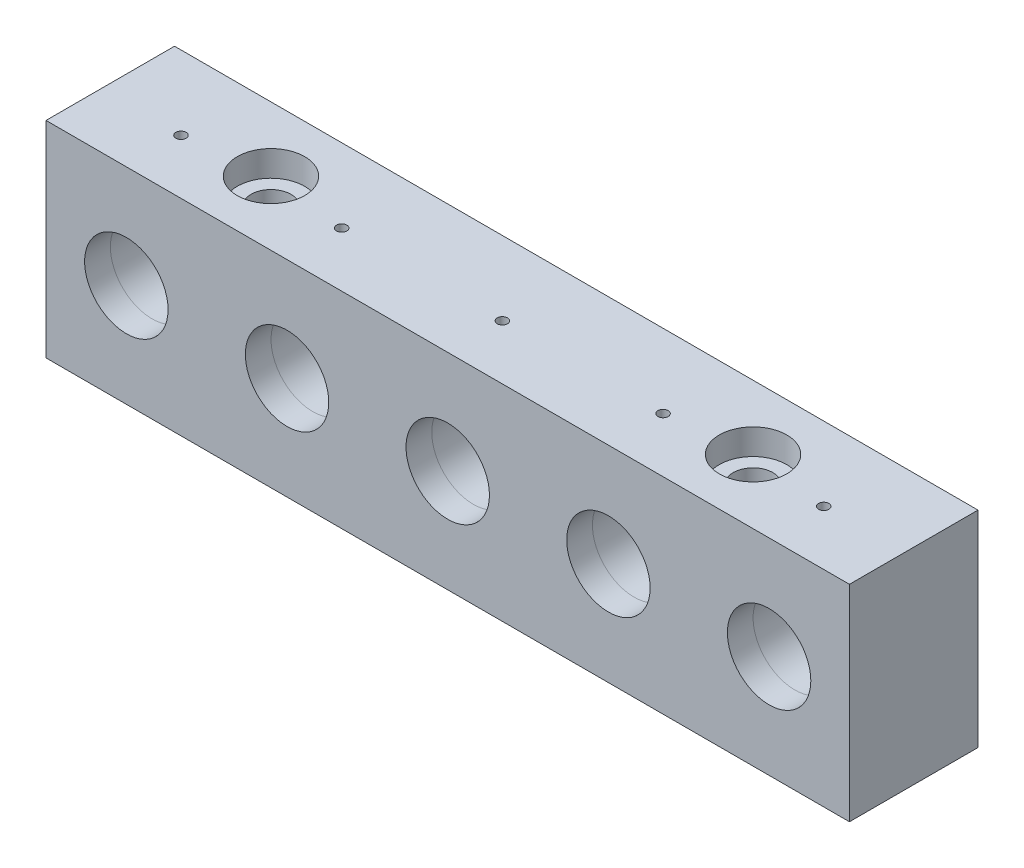
from build123d import *

# Parameters (mm, degrees)
SKETCH1_W                                           = 125
SKETCH1_H                                           = 20
BOSS_EXTRUDE1_DEPTH                                 = 32
SKETCH2_R                                           = 6.4897
CUT_EXTRUDE1_DEPTH                                  = 4
SKETCH3_R                                           = 6.5
CUT_EXTRUDE2_DEPTH                                  = 6.5
CUT_EXTRUDE4_REACH                                  = 132.572
SKETCH8_R                                           = 2.1
SKETCH9_R                                           = 2.825
CUT_EXTRUDE5_DEPTH                                  = 1.1
M3X0_5_TAPPED_HOLE1_AT_2_COUNT                      = 2
M3X0_5_TAPPED_HOLE1_AT_2_PITCH                      = 14
LPATTERN1_COUNT                                     = 5
LPATTERN1_PITCH                                     = 25
M2_TAPPED_HOLE1_REACH                               = 132.572
M2_TAPPED_HOLE1_BORE_R                              = 0.8
CBORE_FOR_M6_HEX_SOCKET_HEAD_CAP_SCREW1_D           = 6.2
CBORE_FOR_M6_HEX_SOCKET_HEAD_CAP_SCREW1_CBORE_D     = 10.5
CBORE_FOR_M6_HEX_SOCKET_HEAD_CAP_SCREW1_CBORE_DEPTH = 4


with BuildPart() as part:
    # Sketch1 → Boss-Extrude1 (new body)
    with BuildSketch(Plane(origin=(0, 0, 0), x_dir=(1, 0, 0), z_dir=(0, 1, 0))):
        with Locations((62.5, 10)):
            Rectangle(SKETCH1_W, SKETCH1_H)
    extrude(amount=BOSS_EXTRUDE1_DEPTH)

    # Sketch2 → Cut-Extrude1 (cut)
    with BuildSketch(Plane.XY):
        with Locations((12.5, 16)):
            Circle(SKETCH2_R)
    cut_extrude1 = extrude(amount=-CUT_EXTRUDE1_DEPTH, mode=Mode.SUBTRACT)

    # Sketch3 → Cut-Extrude2 (cut)
    with BuildSketch(Plane.XY.offset(-4)):
        with Locations((12.5, 16)):
            Circle(SKETCH3_R)
    cut_extrude2 = extrude(amount=-CUT_EXTRUDE2_DEPTH, mode=Mode.SUBTRACT)

    # Sketch6 → M12x0.5 Tapped Hole1 (revolve, cut)
    with BuildSketch(Plane(origin=(12.5, 16, -10.5), x_dir=(0, -1, 0), z_dir=(1, 0, 0))):
        Polygon((0, 0), (0, 7.454948559), (5.75, 4), (5.75, 0), align=None)
    m12x0_5_tapped_hole1 = revolve(axis=Axis((12.5, 16, -4.15), (0, 0, -1)), mode=Mode.SUBTRACT)

    # Sketch8 → Cut-Extrude4 (cut, up to next)
    with BuildSketch(Plane.XY, mode=Mode.PRIVATE) as cut_extrude4_sk1:
        with Locations((12.5, 16)):
            Circle(SKETCH8_R)
    cut_extrude4_tool1 = extrude(cut_extrude4_sk1.sketch, amount=-CUT_EXTRUDE4_REACH, mode=Mode.PRIVATE) & part.part
    cut_extrude4 = cut_extrude4_tool1.solids().sort_by_distance((12.5, 16, 0))[0]
    add(cut_extrude4, mode=Mode.SUBTRACT)

    # Sketch9 → Cut-Extrude5 (cut)
    with BuildSketch(Plane(origin=(0, 0, -20), x_dir=(-1, 0, 0), z_dir=(0, 0, -1))):
        with Locations((-12.5, 16)):
            Circle(SKETCH9_R)
    cut_extrude5 = extrude(amount=-CUT_EXTRUDE5_DEPTH, mode=Mode.SUBTRACT)

    # Sketch11 → M3x0.5 Tapped Hole1 (revolve, cut)
    with BuildSketch(Plane(origin=(19.5, 16, -20), x_dir=(0, 1, 0), z_dir=(1, 0, 0))):
        Polygon((0, 0), (0, 5.251075774), (1.25, 4.5), (1.25, 0), align=None)
    m3x0_5_tapped_hole1 = revolve(axis=Axis((19.5, 16, -26.35), (0, 0, 1)), mode=Mode.SUBTRACT)

    # M3x0.5 Tapped Hole1 at 2: M3x0.5 Tapped Hole1 ×2
    with Locations(*[(-i * M3X0_5_TAPPED_HOLE1_AT_2_PITCH, 0, 0) for i in range(1, M3X0_5_TAPPED_HOLE1_AT_2_COUNT)]):
        add(m3x0_5_tapped_hole1, mode=Mode.SUBTRACT)

    # LPattern1: Cut-Extrude1, Cut-Extrude2, M12x0.5 Tapped Hole1, Cut-Extrude4, Cut-Extrude5, M3x0.5 Tapped Hole1 ×5
    with Locations(*[(i * LPATTERN1_PITCH, 0, 0) for i in range(1, LPATTERN1_COUNT)]):
        add(cut_extrude1, mode=Mode.SUBTRACT)
        add(cut_extrude2, mode=Mode.SUBTRACT)
        add(m12x0_5_tapped_hole1, mode=Mode.SUBTRACT)
        add(cut_extrude4, mode=Mode.SUBTRACT)
        add(cut_extrude5, mode=Mode.SUBTRACT)
        add(m3x0_5_tapped_hole1, mode=Mode.SUBTRACT)

    # LPattern1 copy 1 sketch → LPattern1 copy 1 (revolve, cut)
    with BuildSketch(Plane(origin=(30.5, 16, -20), x_dir=(0, 1, 0), z_dir=(1, 0, 0))):
        Polygon((0, 0), (0, 5.251075774), (1.25, 4.5), (1.25, 0), align=None)
    revolve(axis=Axis((30.5, 16, -26.35), (0, 0, 1)), mode=Mode.SUBTRACT)

    # LPattern1 copy 2 sketch → LPattern1 copy 2 (revolve, cut)
    with BuildSketch(Plane(origin=(55.5, 16, -20), x_dir=(0, 1, 0), z_dir=(1, 0, 0))):
        Polygon((0, 0), (0, 5.251075774), (1.25, 4.5), (1.25, 0), align=None)
    revolve(axis=Axis((55.5, 16, -26.35), (0, 0, 1)), mode=Mode.SUBTRACT)

    # LPattern1 copy 3 sketch → LPattern1 copy 3 (revolve, cut)
    with BuildSketch(Plane(origin=(80.5, 16, -20), x_dir=(0, 1, 0), z_dir=(1, 0, 0))):
        Polygon((0, 0), (0, 5.251075774), (1.25, 4.5), (1.25, 0), align=None)
    revolve(axis=Axis((80.5, 16, -26.35), (0, 0, 1)), mode=Mode.SUBTRACT)

    # LPattern1 copy 4 sketch → LPattern1 copy 4 (revolve, cut)
    with BuildSketch(Plane(origin=(105.5, 16, -20), x_dir=(0, 1, 0), z_dir=(1, 0, 0))):
        Polygon((0, 0), (0, 5.251075774), (1.25, 4.5), (1.25, 0), align=None)
    revolve(axis=Axis((105.5, 16, -26.35), (0, 0, 1)), mode=Mode.SUBTRACT)

    # M2 Tapped Hole1 bore → M2 Tapped Hole1 (cut, up to next)
    with BuildSketch(Plane(origin=(0, 32, 0), x_dir=(1, 0, 0), z_dir=(0, 1, 0)), mode=Mode.PRIVATE) as m2_tapped_hole1_sk1:
        with Locations((12.5, 8.5)):
            Circle(M2_TAPPED_HOLE1_BORE_R)
    m2_tapped_hole1_tool1 = extrude(m2_tapped_hole1_sk1.sketch, amount=-M2_TAPPED_HOLE1_REACH, mode=Mode.PRIVATE) & part.part
    # M2 Tapped Hole1 bore → M2 Tapped Hole1 (cut, up to next)
    with BuildSketch(Plane(origin=(0, 32, 0), x_dir=(1, 0, 0), z_dir=(0, 1, 0)), mode=Mode.PRIVATE) as m2_tapped_hole1_sk2:
        with Locations((37.5, 8.5)):
            Circle(M2_TAPPED_HOLE1_BORE_R)
    m2_tapped_hole1_tool2 = extrude(m2_tapped_hole1_sk2.sketch, amount=-M2_TAPPED_HOLE1_REACH, mode=Mode.PRIVATE) & part.part
    # M2 Tapped Hole1 bore → M2 Tapped Hole1 (cut, up to next)
    with BuildSketch(Plane(origin=(0, 32, 0), x_dir=(1, 0, 0), z_dir=(0, 1, 0)), mode=Mode.PRIVATE) as m2_tapped_hole1_sk3:
        with Locations((62.5, 8.5)):
            Circle(M2_TAPPED_HOLE1_BORE_R)
    m2_tapped_hole1_tool3 = extrude(m2_tapped_hole1_sk3.sketch, amount=-M2_TAPPED_HOLE1_REACH, mode=Mode.PRIVATE) & part.part
    # M2 Tapped Hole1 bore → M2 Tapped Hole1 (cut, up to next)
    with BuildSketch(Plane(origin=(0, 32, 0), x_dir=(1, 0, 0), z_dir=(0, 1, 0)), mode=Mode.PRIVATE) as m2_tapped_hole1_sk4:
        with Locations((87.5, 8.5)):
            Circle(M2_TAPPED_HOLE1_BORE_R)
    m2_tapped_hole1_tool4 = extrude(m2_tapped_hole1_sk4.sketch, amount=-M2_TAPPED_HOLE1_REACH, mode=Mode.PRIVATE) & part.part
    # M2 Tapped Hole1 bore → M2 Tapped Hole1 (cut, up to next)
    with BuildSketch(Plane(origin=(0, 32, 0), x_dir=(1, 0, 0), z_dir=(0, 1, 0)), mode=Mode.PRIVATE) as m2_tapped_hole1_sk5:
        with Locations((112.5, 8.5)):
            Circle(M2_TAPPED_HOLE1_BORE_R)
    m2_tapped_hole1_tool5 = extrude(m2_tapped_hole1_sk5.sketch, amount=-M2_TAPPED_HOLE1_REACH, mode=Mode.PRIVATE) & part.part
    add(m2_tapped_hole1_tool1.solids().sort_by_distance((12.5, 32, -8.5))[0], mode=Mode.SUBTRACT)
    add(m2_tapped_hole1_tool2.solids().sort_by_distance((37.5, 32, -8.5))[0], mode=Mode.SUBTRACT)
    add(m2_tapped_hole1_tool3.solids().sort_by_distance((62.5, 32, -8.5))[0], mode=Mode.SUBTRACT)
    add(m2_tapped_hole1_tool4.solids().sort_by_distance((87.5, 32, -8.5))[0], mode=Mode.SUBTRACT)
    add(m2_tapped_hole1_tool5.solids().sort_by_distance((112.5, 32, -8.5))[0], mode=Mode.SUBTRACT)

    # CBORE for M6 Hex Socket Head Cap Screw1 (through all)
    with Locations(Plane(origin=(0, 32, 0), x_dir=(1, 0, 0), z_dir=(0, 1, 0))):
        with Locations((25, 10), (100, 10)):
            CounterBoreHole(CBORE_FOR_M6_HEX_SOCKET_HEAD_CAP_SCREW1_D / 2, CBORE_FOR_M6_HEX_SOCKET_HEAD_CAP_SCREW1_CBORE_D / 2, CBORE_FOR_M6_HEX_SOCKET_HEAD_CAP_SCREW1_CBORE_DEPTH)


solid = part.part
